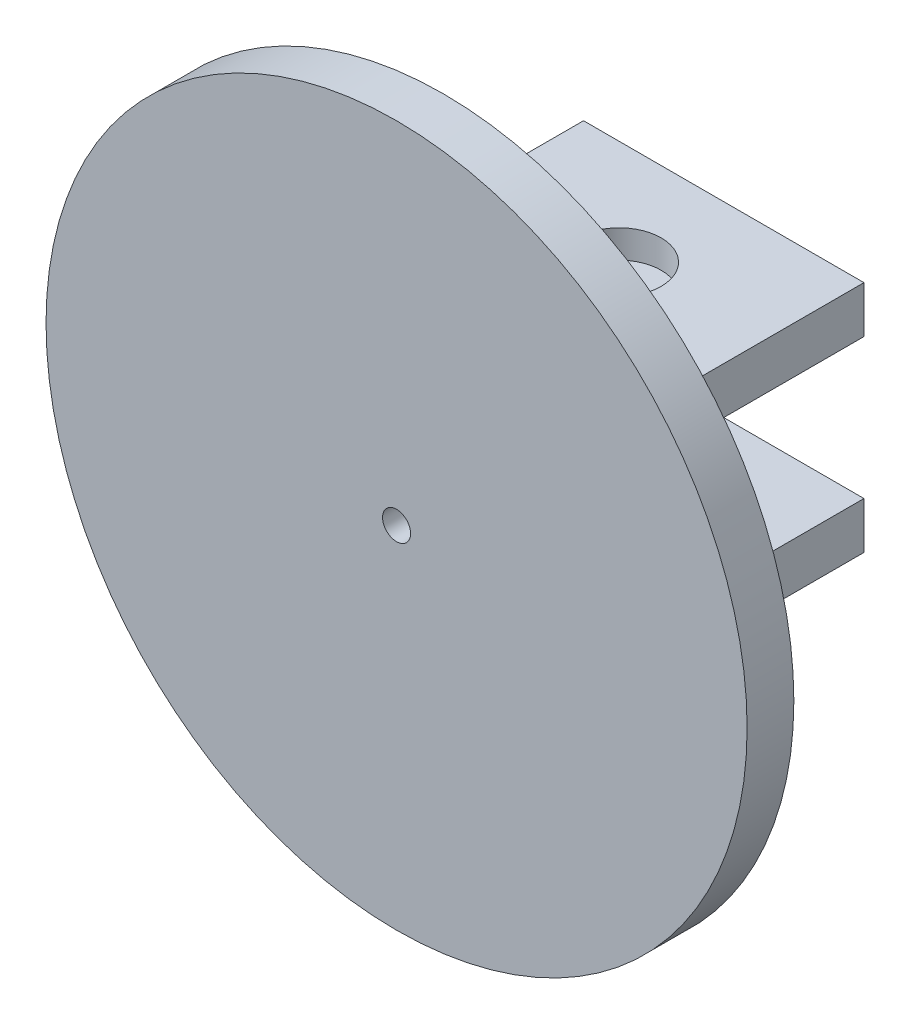
from build123d import *

# Parameters (mm, degrees)
SKETCH1_R           = 75
BOSS_EXTRUDE1_DEPTH = 10
CUT_EXTRUDE1_REACH  = 12
SKETCH2_R           = 3
SKETCH3_W           = 60
SKETCH3_H           = 10
BOSS_EXTRUDE2_DEPTH = 60
SKETCH4_R           = 9
CUT_EXTRUDE2_DEPTH  = 101
SKETCH6_R           = 9
SKETCH6_R_2         = 4.5
BOSS_EXTRUDE3_DEPTH = 4
SKETCH9_R           = 2.25
CUT_EXTRUDE5_DEPTH  = 10


with BuildPart() as part:
    # Sketch1 → Boss-Extrude1 (new body)
    with BuildSketch(Plane.XY):
        Circle(SKETCH1_R)
    extrude(amount=BOSS_EXTRUDE1_DEPTH)

    # Sketch2 → Cut-Extrude1 (cut, up to next)
    with BuildSketch(Plane.XY.offset(10), mode=Mode.PRIVATE) as cut_extrude1_sk1:
        Circle(SKETCH2_R)
    cut_extrude1_tool1 = extrude(cut_extrude1_sk1.sketch, amount=-CUT_EXTRUDE1_REACH, mode=Mode.PRIVATE) & part.part
    add(cut_extrude1_tool1.solids().sort_by_distance((0, 0, 10))[0], mode=Mode.SUBTRACT)

    # Sketch3 → Boss-Extrude2 (add)
    with BuildSketch(Plane(origin=(0, 0, 0), x_dir=(-1, 0, 0), z_dir=(0, 0, -1))):
        with Locations((0, 20)):
            Rectangle(SKETCH3_W, SKETCH3_H)
        with Locations((0, -20)):
            Rectangle(SKETCH3_W, SKETCH3_H)
    extrude(amount=BOSS_EXTRUDE2_DEPTH)

    # Sketch4 → Cut-Extrude2 (cut, through all)
    with BuildSketch(Plane.XZ.offset(25)):
        with Locations((0, -37.6)):
            Circle(SKETCH4_R)
    extrude(amount=-CUT_EXTRUDE2_DEPTH, mode=Mode.SUBTRACT)

    # Sketch6 → Boss-Extrude3 (add)
    with BuildSketch(Plane.XZ.offset(-15)):
        with Locations((0, -37.6)):
            Circle(SKETCH6_R)
        with Locations((0, -37.6)):
            Circle(SKETCH6_R_2, mode=Mode.SUBTRACT)
    boss_extrude3 = extrude(amount=-BOSS_EXTRUDE3_DEPTH)

    # Sketch9 → Cut-Extrude5 (cut)
    with BuildSketch(Plane.XZ.offset(25)):
        with Locations((-5, -2.5)):
            Circle(SKETCH9_R)
        with Locations((5, -2.5)):
            Circle(SKETCH9_R)
        with Locations((-5, -53)):
            Circle(SKETCH9_R)
        with Locations((5.285793913, -53)):
            Circle(SKETCH9_R)
    extrude(amount=-CUT_EXTRUDE5_DEPTH, mode=Mode.SUBTRACT)

    # Mirror1: Boss-Extrude3 across plane
    add(boss_extrude3.mirror(Plane.ZX))


solid = part.part
